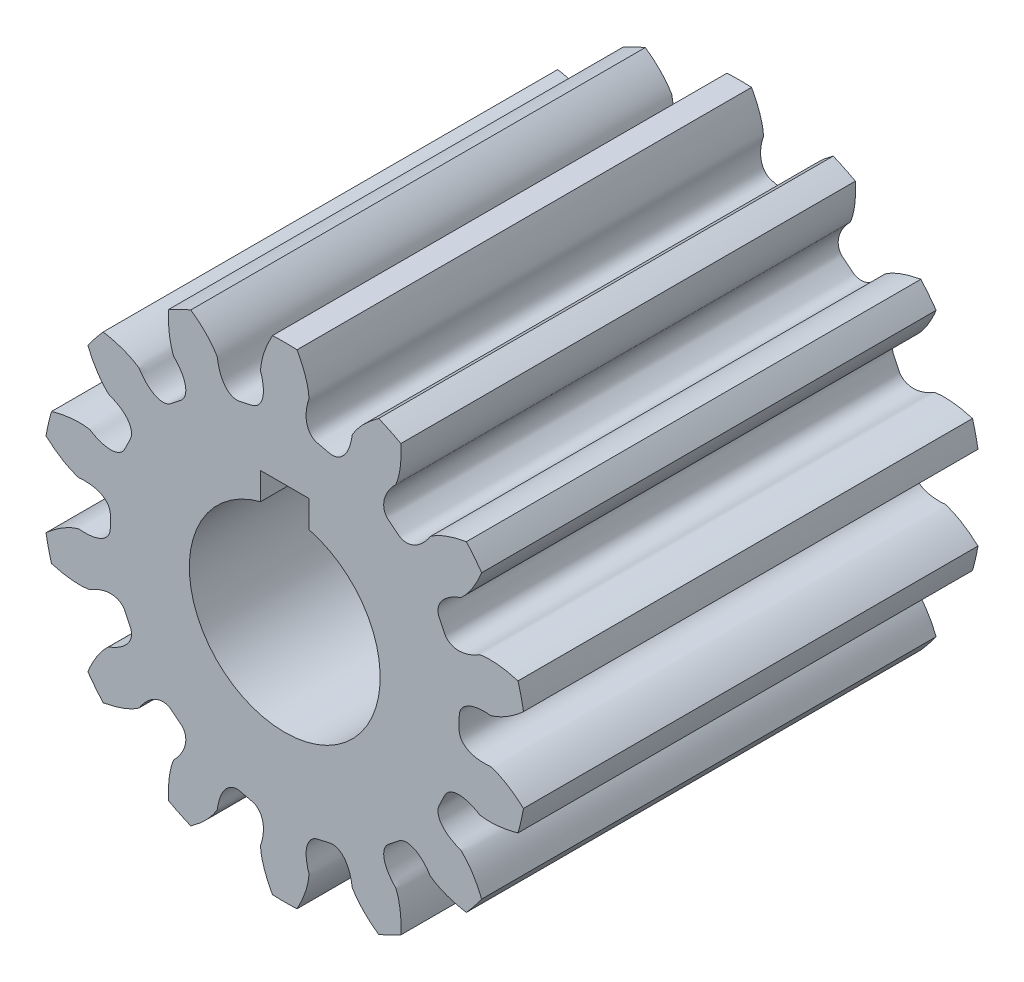
from build123d import *

# Parameters (mm, degrees)
BOSS_EXTRUDE1_DEPTH = 19.05


with BuildPart() as part:
    # Sketch1 → Boss-Extrude1 (new body)
    with BuildSketch(Plane.XY.offset(9.525)):
        with BuildLine():
            ThreePointArc((8.254240281, 5.923944149), (7.943407743, 6.334656292), (7.612159758, 6.729087659))
            add(Edge.make_bspline(
                [(4.866510484, 8.91866989), (4.871788095, 8.831889334), (4.876863236, 8.693415419), (4.875897418, 8.506237979), (4.870472214, 8.36041887), (4.860992929, 8.223670591), (4.848034499, 8.096094305), (4.832174578, 7.977763161), (4.813989816, 7.868724096), (4.794062548, 7.768992217), (4.772953915, 7.67856936), (4.751286261, 7.597384156), (4.729474057, 7.525484762), (4.708567258, 7.462432099), (4.682440878, 7.395927708), (4.653018269, 7.304855443), (4.571118248, 7.24170707), (4.512717244, 7.168958718), (4.466033353, 7.111860953), (4.42312977, 7.054541235), (4.383170204, 6.997585971), (4.346330736, 6.940873063), (4.31253115, 6.884445397), (4.281762968, 6.828283724), (4.254008713, 6.772361484), (4.229267489, 6.716626724), (4.207555117, 6.661002359), (4.188913451, 6.60538159), (4.173420903, 6.549625086), (4.161207451, 6.493559507), (4.152474573, 6.436979817), (4.147521039, 6.37965888), (4.146774005, 6.321370083), (4.150822138, 6.261931608), (4.160440272, 6.201282083), (4.176588359, 6.13959837), (4.200340159, 6.077441385), (4.232748668, 6.015934806), (4.274448355, 5.956743468), (4.321011181, 5.907396991), (4.416018599, 5.826894138), (4.564101629, 5.72320242), (4.698145153, 5.601905718), (4.797770771, 5.527193905), (4.856241232, 5.49277913), (4.923227573, 5.465296254), (4.990403626, 5.447386795), (5.056287478, 5.438061733), (5.120017939, 5.436044429), (5.18128709, 5.440163231), (5.240136113, 5.449442898), (5.296797257, 5.46314168), (5.351578774, 5.480726127), (5.404796645, 5.501830218), (5.456738794, 5.526213219), (5.507649949, 5.553724325), (5.557728029, 5.584275392), (5.607126317, 5.617820974), (5.65595825, 5.654344035), (5.7043025, 5.693846302), (5.752209518, 5.73634021), (5.79970131, 5.781848707), (5.846794754, 5.830384341), (5.89343019, 5.882015776), (5.939765838, 5.936598515), (5.9850439, 5.99481739), (6.042972853, 6.06794219), (6.086313495, 6.161840642), (6.168555242, 6.21079105), (6.227578563, 6.251061007), (6.284398162, 6.285474166), (6.349641217, 6.322738612), (6.423969432, 6.361928421), (6.507428086, 6.402628795), (6.600225244, 6.444248875), (6.702483982, 6.486241182), (6.814319153, 6.528034618), (6.935813313, 6.569056548), (7.067023688, 6.608727522), (7.207979586, 6.64646451), (7.390249182, 6.689057011), (7.526380592, 6.714922459), (7.612159758, 6.729087659)],
                knots=[0.010402665, 0.010402665, 0.010402665, 0.010402665, 0.046486175, 0.067894282, 0.088079069, 0.107040535, 0.124778681, 0.141293506, 0.156585011, 0.170653196, 0.18349806, 0.195119605, 0.205517828, 0.214692732, 0.222644315, 0.235305165, 0.253443912, 0.263936227, 0.274128925, 0.284030449, 0.293650544, 0.303000508, 0.312093491, 0.320944865, 0.329572668, 0.337998146, 0.346246397, 0.354347134, 0.36233556, 0.370253316, 0.378149436, 0.386081099, 0.394113848, 0.402320657, 0.410778894, 0.419563951, 0.428738357, 0.438336273, 0.448346034, 0.458697354, 0.466396858, 0.5, 0.533603142, 0.541302646, 0.551653966, 0.561663727, 0.571261643, 0.580436049, 0.589221106, 0.597679343, 0.605886152, 0.613918901, 0.621850564, 0.629746684, 0.63766444, 0.645652866, 0.653753603, 0.662001854, 0.670427332, 0.679055135, 0.687906509, 0.696999492, 0.706349456, 0.715969551, 0.725871075, 0.736063773, 0.746556088, 0.764694835, 0.777355685, 0.785307268, 0.794482172, 0.804880395, 0.81650194, 0.829346804, 0.843414989, 0.858706494, 0.875221319, 0.892959465, 0.911920931, 0.932105718, 0.953513825, 0.989597335, 0.989597335, 0.989597335, 0.989597335], degree=3))
            ThreePointArc((4.866510484, 8.91866989), (4.408258723, 9.15384356), (3.938677245, 9.365490829))
            add(Edge.make_bspline(
                [(0.514908601, 10.146943679), (0.557316237, 10.071046969), (0.62197036, 9.948488304), (0.702313437, 9.779428205), (0.760694036, 9.64569582), (0.811486351, 9.51837697), (0.855164485, 9.397812256), (0.892217149, 9.284318218), (0.923143522, 9.178187342), (0.948461715, 9.079685906), (0.9686765, 8.989059035), (0.984379558, 8.906512451), (0.99592342, 8.832269374), (1.00444457, 8.766389768), (1.009760689, 8.695135571), (1.022766609, 8.600316304), (0.976376291, 8.507886498), (0.955323132, 8.417003252), (0.938036192, 8.345304562), (0.924251493, 8.275046113), (0.91296113, 8.206393387), (0.904376725, 8.139312777), (0.898407398, 8.073808116), (0.895053859, 8.009858383), (0.894311891, 7.947432066), (0.896203224, 7.886481967), (0.900775561, 7.826945502), (0.908112947, 7.768744604), (0.918346484, 7.711787765), (0.931668487, 7.655975206), (0.948349444, 7.601209613), (0.968757086, 7.547415975), (0.993374593, 7.494575458), (1.022811223, 7.442779661), (1.057791704, 7.39230948), (1.099104188, 7.343740767), (1.147472725, 7.298044778), (1.203358488, 7.25669079), (1.266610767, 7.221454053), (1.329973057, 7.197197267), (1.450500662, 7.165888876), (1.628909012, 7.136716686), (1.802306721, 7.085591439), (1.924482542, 7.061504356), (1.992094618, 7.055867098), (2.064371599, 7.060170166), (2.132665754, 7.073180898), (2.196071047, 7.09336524), (2.254365483, 7.119199323), (2.307779999, 7.149493923), (2.35677484, 7.183388248), (2.401881089, 7.220314773), (2.443607924, 7.259926623), (2.482398847, 7.302031121), (2.518617719, 7.346536299), (2.552550463, 7.393412472), (2.584413643, 7.442666096), (2.61436508, 7.494322736), (2.642514369, 7.548416258), (2.668931643, 7.604982355), (2.693656958, 7.664054119), (2.716700187, 7.725661774), (2.738071092, 7.789823949), (2.757686128, 7.856576622), (2.775750541, 7.925858254), (2.791284442, 7.997957063), (2.811748964, 8.088974663), (2.810056522, 8.192379044), (2.862914989, 8.272165195), (2.898620684, 8.334056431), (2.934882065, 8.389714716), (2.977495588, 8.451596723), (3.027459175, 8.519155324), (3.084993594, 8.592036447), (3.150542668, 8.669798022), (3.224454829, 8.752000187), (3.307081343, 8.838178233), (3.398745051, 8.927852055), (3.499748924, 9.020524416), (3.610372334, 9.115682739), (3.756111372, 9.23314107), (3.867538937, 9.315510239), (3.938677245, 9.365490829)],
                knots=[0.010402665, 0.010402665, 0.010402665, 0.010402665, 0.046486175, 0.067894282, 0.088079069, 0.107040535, 0.124778681, 0.141293506, 0.156585011, 0.170653196, 0.18349806, 0.195119605, 0.205517828, 0.214692732, 0.222644315, 0.235305165, 0.253443912, 0.263936227, 0.274128925, 0.284030449, 0.293650544, 0.303000508, 0.312093491, 0.320944865, 0.329572668, 0.337998146, 0.346246397, 0.354347134, 0.36233556, 0.370253316, 0.378149436, 0.386081099, 0.394113848, 0.402320657, 0.410778894, 0.419563951, 0.428738357, 0.438336273, 0.448346034, 0.458697354, 0.466396858, 0.5, 0.533603142, 0.541302646, 0.551653966, 0.561663727, 0.571261643, 0.580436049, 0.589221106, 0.597679343, 0.605886152, 0.613918901, 0.621850564, 0.629746684, 0.63766444, 0.645652866, 0.653753603, 0.662001854, 0.670427332, 0.679055135, 0.687906509, 0.696999492, 0.706349456, 0.715969551, 0.725871075, 0.736063773, 0.746556088, 0.764694835, 0.777355685, 0.785307268, 0.794482172, 0.804880395, 0.81650194, 0.829346804, 0.843414989, 0.858706494, 0.875221319, 0.892959465, 0.911920931, 0.932105718, 0.953513825, 0.989597335, 0.989597335, 0.989597335, 0.989597335], degree=3))
            ThreePointArc((0.514908601, 10.146943679), (0, 10.159999847), (-0.514908601, 10.146943679))
            add(Edge.make_bspline(
                [(-3.938677245, 9.365490829), (-3.867538937, 9.315510239), (-3.756111372, 9.23314107), (-3.610372334, 9.115682739), (-3.499748924, 9.020524416), (-3.398745051, 8.927852055), (-3.307081343, 8.838178233), (-3.224454829, 8.752000187), (-3.150542669, 8.669798022), (-3.084993594, 8.592036447), (-3.027459175, 8.519155324), (-2.977495588, 8.451596723), (-2.934882065, 8.389714716), (-2.898620684, 8.334056431), (-2.862914989, 8.272165195), (-2.810056522, 8.192379044), (-2.811748964, 8.088974663), (-2.791284442, 7.997957063), (-2.775750541, 7.925858254), (-2.757686128, 7.856576622), (-2.738071092, 7.789823949), (-2.716700187, 7.725661774), (-2.693656958, 7.664054119), (-2.668931643, 7.604982355), (-2.642514369, 7.548416258), (-2.61436508, 7.494322736), (-2.584413643, 7.442666096), (-2.552550463, 7.393412472), (-2.518617719, 7.346536299), (-2.482398847, 7.302031121), (-2.443607924, 7.259926623), (-2.401881089, 7.220314773), (-2.35677484, 7.183388248), (-2.307779999, 7.149493923), (-2.254365483, 7.119199323), (-2.196071047, 7.09336524), (-2.132665754, 7.073180898), (-2.064371599, 7.060170166), (-1.992094618, 7.055867098), (-1.924482542, 7.061504356), (-1.802306721, 7.085591439), (-1.628909012, 7.136716686), (-1.450500662, 7.165888876), (-1.329973057, 7.197197267), (-1.266610767, 7.221454053), (-1.203358488, 7.25669079), (-1.147472726, 7.298044778), (-1.099104188, 7.343740767), (-1.057791705, 7.39230948), (-1.022811223, 7.442779661), (-0.993374593, 7.494575458), (-0.968757086, 7.547415975), (-0.948349444, 7.601209613), (-0.931668487, 7.655975206), (-0.918346484, 7.711787765), (-0.908112947, 7.768744604), (-0.900775561, 7.826945502), (-0.896203224, 7.886481967), (-0.894311891, 7.947432066), (-0.895053859, 8.009858383), (-0.898407398, 8.073808116), (-0.904376725, 8.139312777), (-0.91296113, 8.206393387), (-0.924251493, 8.275046113), (-0.938036192, 8.345304562), (-0.955323132, 8.417003252), (-0.976376291, 8.507886498), (-1.022766609, 8.600316304), (-1.009760689, 8.695135571), (-1.00444457, 8.766389768), (-0.99592342, 8.832269374), (-0.984379558, 8.906512451), (-0.9686765, 8.989059035), (-0.948461715, 9.079685906), (-0.923143522, 9.178187342), (-0.892217149, 9.284318218), (-0.855164485, 9.397812256), (-0.811486351, 9.51837697), (-0.760694037, 9.64569582), (-0.702313437, 9.779428205), (-0.62197036, 9.948488304), (-0.557316237, 10.071046969), (-0.514908601, 10.146943679)],
                knots=[0.010402665, 0.010402665, 0.010402665, 0.010402665, 0.046486175, 0.067894282, 0.088079069, 0.107040535, 0.124778681, 0.141293506, 0.156585011, 0.170653196, 0.18349806, 0.195119605, 0.205517828, 0.214692732, 0.222644315, 0.235305165, 0.253443912, 0.263936227, 0.274128925, 0.284030449, 0.293650544, 0.303000508, 0.312093491, 0.320944865, 0.329572668, 0.337998146, 0.346246397, 0.354347134, 0.36233556, 0.370253316, 0.378149436, 0.386081099, 0.394113848, 0.402320657, 0.410778894, 0.419563951, 0.428738357, 0.438336273, 0.448346034, 0.458697354, 0.466396858, 0.5, 0.533603142, 0.541302646, 0.551653966, 0.561663727, 0.571261643, 0.580436049, 0.589221106, 0.597679343, 0.605886152, 0.613918901, 0.621850564, 0.629746684, 0.63766444, 0.645652866, 0.653753603, 0.662001854, 0.670427332, 0.679055135, 0.687906509, 0.696999492, 0.706349456, 0.715969551, 0.725871075, 0.736063773, 0.746556088, 0.764694835, 0.777355685, 0.785307268, 0.794482172, 0.804880395, 0.81650194, 0.829346804, 0.843414989, 0.858706494, 0.875221319, 0.892959465, 0.911920931, 0.932105718, 0.953513825, 0.989597335, 0.989597335, 0.989597335, 0.989597335], degree=3))
            ThreePointArc((-3.938677245, 9.365490829), (-4.408258723, 9.15384356), (-4.866510484, 8.91866989))
            add(Edge.make_bspline(
                [(-7.612159758, 6.729087659), (-7.526380592, 6.714922459), (-7.390249182, 6.689057011), (-7.207979586, 6.64646451), (-7.067023688, 6.608727522), (-6.935813313, 6.569056548), (-6.814319153, 6.528034618), (-6.702483982, 6.486241182), (-6.600225244, 6.444248875), (-6.507428086, 6.402628795), (-6.423969432, 6.361928421), (-6.349641217, 6.322738612), (-6.284398162, 6.285474166), (-6.227578563, 6.251061007), (-6.168555242, 6.21079105), (-6.086313495, 6.161840642), (-6.042972853, 6.06794219), (-5.9850439, 5.99481739), (-5.939765838, 5.936598515), (-5.89343019, 5.882015776), (-5.846794754, 5.830384341), (-5.79970131, 5.781848707), (-5.752209518, 5.73634021), (-5.704302501, 5.693846302), (-5.65595825, 5.654344035), (-5.607126317, 5.617820974), (-5.557728029, 5.584275392), (-5.507649949, 5.553724325), (-5.456738794, 5.526213219), (-5.404796645, 5.501830218), (-5.351578774, 5.480726127), (-5.296797257, 5.46314168), (-5.240136113, 5.449442898), (-5.18128709, 5.440163231), (-5.120017939, 5.436044429), (-5.056287478, 5.438061733), (-4.990403626, 5.447386795), (-4.923227573, 5.465296254), (-4.856241232, 5.49277913), (-4.797770771, 5.527193905), (-4.698145153, 5.601905718), (-4.564101629, 5.72320242), (-4.416018599, 5.826894138), (-4.321011181, 5.907396991), (-4.274448355, 5.956743468), (-4.232748669, 6.015934806), (-4.200340159, 6.077441385), (-4.176588359, 6.13959837), (-4.160440272, 6.201282083), (-4.150822138, 6.261931608), (-4.146774005, 6.321370083), (-4.147521039, 6.37965888), (-4.152474573, 6.436979817), (-4.161207451, 6.493559507), (-4.173420903, 6.549625086), (-4.188913451, 6.60538159), (-4.207555117, 6.661002359), (-4.229267489, 6.716626724), (-4.254008713, 6.772361484), (-4.281762968, 6.828283724), (-4.31253115, 6.884445397), (-4.346330736, 6.940873063), (-4.383170204, 6.997585971), (-4.42312977, 7.054541235), (-4.466033354, 7.111860953), (-4.512717244, 7.168958718), (-4.571118248, 7.24170707), (-4.653018269, 7.304855443), (-4.682440878, 7.395927708), (-4.708567258, 7.462432099), (-4.729474057, 7.525484762), (-4.751286261, 7.597384156), (-4.772953915, 7.67856936), (-4.794062548, 7.768992217), (-4.813989816, 7.868724096), (-4.832174578, 7.977763161), (-4.848034499, 8.096094305), (-4.860992929, 8.223670591), (-4.870472214, 8.36041887), (-4.875897418, 8.506237979), (-4.876863236, 8.693415419), (-4.871788095, 8.831889334), (-4.866510484, 8.91866989)],
                knots=[0.010402665, 0.010402665, 0.010402665, 0.010402665, 0.046486175, 0.067894282, 0.088079069, 0.107040535, 0.124778681, 0.141293506, 0.156585011, 0.170653196, 0.18349806, 0.195119605, 0.205517828, 0.214692732, 0.222644315, 0.235305165, 0.253443912, 0.263936227, 0.274128925, 0.284030449, 0.293650544, 0.303000508, 0.312093491, 0.320944865, 0.329572668, 0.337998146, 0.346246397, 0.354347134, 0.36233556, 0.370253316, 0.378149436, 0.386081099, 0.394113848, 0.402320657, 0.410778894, 0.419563951, 0.428738357, 0.438336273, 0.448346034, 0.458697354, 0.466396858, 0.5, 0.533603142, 0.541302646, 0.551653966, 0.561663727, 0.571261643, 0.580436049, 0.589221106, 0.597679343, 0.605886152, 0.613918901, 0.621850564, 0.629746684, 0.63766444, 0.645652866, 0.653753603, 0.662001854, 0.670427332, 0.679055135, 0.687906509, 0.696999492, 0.706349456, 0.715969551, 0.725871075, 0.736063773, 0.746556088, 0.764694835, 0.777355685, 0.785307268, 0.794482172, 0.804880395, 0.81650194, 0.829346804, 0.843414989, 0.858706494, 0.875221319, 0.892959465, 0.911920931, 0.932105718, 0.953513825, 0.989597335, 0.989597335, 0.989597335, 0.989597335], degree=3))
            ThreePointArc((-7.612159758, 6.729087659), (-7.943407743, 6.334656292), (-8.254240281, 5.923944149))
            add(Edge.make_bspline(
                [(-9.777960674, 2.759906152), (-9.694530266, 2.784361933), (-9.560657506, 2.820123174), (-9.377958081, 2.860832471), (-9.23458774, 2.887991091), (-9.099158686, 2.909178827), (-8.971897482, 2.924933686), (-8.853003983, 2.935802563), (-8.742652264, 2.942337206), (-8.640986637, 2.945101987), (-8.548133758, 2.94464357), (-8.46416253, 2.941584576), (-8.389212131, 2.936318371), (-8.32308813, 2.929966286), (-8.252437477, 2.919293568), (-8.157101437, 2.910874131), (-8.077311856, 2.845079349), (-7.993392012, 2.804330611), (-7.927337664, 2.771522632), (-7.861908125, 2.742449568), (-7.797489008, 2.71616561), (-7.734000459, 2.692869594), (-7.671466436, 2.672473771), (-7.60986629, 2.654974159), (-7.549170234, 2.64035963), (-7.48932742, 2.628640871), (-7.430266217, 2.61985046), (-7.371891816, 2.614052964), (-7.314085828, 2.611355836), (-7.256708181, 2.611924366), (-7.199603814, 2.616000605), (-7.142617767, 2.623926375), (-7.085624162, 2.636168548), (-7.028576727, 2.653341491), (-6.971588049, 2.676214267), (-6.915044163, 2.705683406), (-6.859730856, 2.742670929), (-6.806977947, 2.787953391), (-6.758549712, 2.841778891), (-6.720801658, 2.898154913), (-6.663458319, 3.008693867), (-6.595317944, 3.176137725), (-6.506889894, 3.333811553), (-6.456220046, 3.447564291), (-6.435679024, 3.512226783), (-6.423791064, 3.583649152), (-6.42127871, 3.653126191), (-6.426847983, 3.719433219), (-6.43906262, 3.782014716), (-6.456711823, 3.840831202), (-6.478853969, 3.896139837), (-6.504817584, 3.948332102), (-6.534151187, 3.997827224), (-6.566568245, 4.04501471), (-6.601898128, 4.090228833), (-6.640048272, 4.133741742), (-6.680976781, 4.175766008), (-6.724673459, 4.216461184), (-6.771146937, 4.255941653), (-6.820416408, 4.29428373), (-6.872505219, 4.331533835), (-6.92744064, 4.367708315), (-6.985238662, 4.402820833), (-7.04595295, 4.436797947), (-7.109477837, 4.469826061), (-7.17631236, 4.501013989), (-7.260494174, 4.541218744), (-7.361682596, 4.562578374), (-7.427706225, 4.631865658), (-7.480100454, 4.680448233), (-7.526294354, 4.728185598), (-7.577142448, 4.783500754), (-7.631889271, 4.847244852), (-7.690140499, 4.919554338), (-7.751366387, 5.000763539), (-7.815060569, 5.09111427), (-7.880691823, 5.190845585), (-7.947720242, 5.300165394), (-8.015593636, 5.419258429), (-8.083750117, 5.548282999), (-8.165833536, 5.716504993), (-8.221342572, 5.8434677), (-8.254240281, 5.923944149)],
                knots=[0.010402665, 0.010402665, 0.010402665, 0.010402665, 0.046486175, 0.067894282, 0.088079069, 0.107040535, 0.124778681, 0.141293506, 0.156585011, 0.170653196, 0.18349806, 0.195119605, 0.205517828, 0.214692732, 0.222644315, 0.235305165, 0.253443912, 0.263936227, 0.274128925, 0.284030449, 0.293650544, 0.303000508, 0.312093491, 0.320944865, 0.329572668, 0.337998146, 0.346246397, 0.354347134, 0.36233556, 0.370253316, 0.378149436, 0.386081099, 0.394113848, 0.402320657, 0.410778894, 0.419563951, 0.428738357, 0.438336273, 0.448346034, 0.458697354, 0.466396858, 0.5, 0.533603142, 0.541302646, 0.551653966, 0.561663727, 0.571261643, 0.580436049, 0.589221106, 0.597679343, 0.605886152, 0.613918901, 0.621850564, 0.629746684, 0.63766444, 0.645652866, 0.653753603, 0.662001854, 0.670427332, 0.679055135, 0.687906509, 0.696999492, 0.706349456, 0.715969551, 0.725871075, 0.736063773, 0.746556088, 0.764694835, 0.777355685, 0.785307268, 0.794482172, 0.804880395, 0.81650194, 0.829346804, 0.843414989, 0.858706494, 0.875221319, 0.892959465, 0.911920931, 0.932105718, 0.953513825, 0.989597335, 0.989597335, 0.989597335, 0.989597335], degree=3))
            ThreePointArc((-9.777960674, 2.759906152), (-9.905267439, 2.260812655), (-10.007116559, 1.755908617))
            add(Edge.make_bspline(
                [(-10.007116559, -1.755908617), (-9.942559325, -1.697675622), (-9.837460357, -1.607370644), (-9.690516965, -1.491422525), (-9.573128435, -1.404747394), (-9.460304088, -1.326897439), (-9.352481482, -1.257486235), (-9.250077969, -1.196107759), (-9.153489782, -1.142340433), (-9.06309181, -1.095738389), (-8.979235357, -1.055864054), (-8.902252647, -1.022186361), (-8.83243975, -0.99441129), (-8.770108018, -0.971444191), (-8.70182326, -0.950405808), (-8.612275399, -0.916626702), (-8.511840185, -0.94128635), (-8.418550803, -0.941588238), (-8.344803043, -0.942487299), (-8.273238735, -0.940292412), (-8.203794935, -0.936023032), (-8.136485966, -0.929465368), (-8.071295343, -0.920708874), (-8.008202731, -0.909748178), (-7.947176468, -0.896580381), (-7.888175377, -0.881173795), (-7.831149056, -0.863467986), (-7.776040098, -0.843363646), (-7.722788462, -0.820712596), (-7.671339665, -0.79530514), (-7.621659022, -0.766855919), (-7.57375523, -0.734989728), (-7.527717446, -0.699231313), (-7.483770545, -0.659007071), (-7.442349645, -0.613672951), (-7.404191544, -0.562588703), (-7.370404261, -0.505264552), (-7.342522856, -0.441577834), (-7.322244534, -0.37207051), (-7.312695352, -0.304899202), (-7.308991843, -0.180426704), (-7.320250653, 0), (-7.308991843, 0.180426704), (-7.312695352, 0.304899202), (-7.322244534, 0.37207051), (-7.342522856, 0.441577834), (-7.370404261, 0.505264552), (-7.404191544, 0.562588703), (-7.442349645, 0.613672951), (-7.483770545, 0.659007071), (-7.527717446, 0.699231313), (-7.57375523, 0.734989728), (-7.621659022, 0.766855919), (-7.671339665, 0.79530514), (-7.722788462, 0.820712596), (-7.776040098, 0.843363646), (-7.831149056, 0.863467986), (-7.888175377, 0.881173795), (-7.947176468, 0.896580381), (-8.008202731, 0.909748178), (-8.071295343, 0.920708874), (-8.136485966, 0.929465368), (-8.203794935, 0.936023032), (-8.273238735, 0.940292412), (-8.344803043, 0.942487299), (-8.418550803, 0.941588238), (-8.511840185, 0.94128635), (-8.612275399, 0.916626702), (-8.70182326, 0.950405808), (-8.770108018, 0.971444191), (-8.83243975, 0.99441129), (-8.902252647, 1.022186361), (-8.979235357, 1.055864054), (-9.06309181, 1.095738389), (-9.153489782, 1.142340433), (-9.250077969, 1.196107759), (-9.352481482, 1.257486235), (-9.460304088, 1.326897439), (-9.573128435, 1.404747394), (-9.690516965, 1.491422525), (-9.837460357, 1.607370644), (-9.942559325, 1.697675622), (-10.007116559, 1.755908617)],
                knots=[0.010402665, 0.010402665, 0.010402665, 0.010402665, 0.046486175, 0.067894282, 0.088079069, 0.107040535, 0.124778681, 0.141293506, 0.156585011, 0.170653196, 0.18349806, 0.195119605, 0.205517828, 0.214692732, 0.222644315, 0.235305165, 0.253443912, 0.263936227, 0.274128925, 0.284030449, 0.293650544, 0.303000508, 0.312093491, 0.320944865, 0.329572668, 0.337998146, 0.346246397, 0.354347134, 0.36233556, 0.370253316, 0.378149436, 0.386081099, 0.394113848, 0.402320657, 0.410778894, 0.419563951, 0.428738357, 0.438336273, 0.448346034, 0.458697354, 0.466396858, 0.5, 0.533603142, 0.541302646, 0.551653966, 0.561663727, 0.571261643, 0.580436049, 0.589221106, 0.597679343, 0.605886152, 0.613918901, 0.621850564, 0.629746684, 0.63766444, 0.645652866, 0.653753603, 0.662001854, 0.670427332, 0.679055135, 0.687906509, 0.696999492, 0.706349456, 0.715969551, 0.725871075, 0.736063773, 0.746556088, 0.764694835, 0.777355685, 0.785307268, 0.794482172, 0.804880395, 0.81650194, 0.829346804, 0.843414989, 0.858706494, 0.875221319, 0.892959465, 0.911920931, 0.932105718, 0.953513825, 0.989597335, 0.989597335, 0.989597335, 0.989597335], degree=3))
            ThreePointArc((-10.007116559, -1.755908617), (-9.905267439, -2.260812655), (-9.777960674, -2.759906152))
            add(Edge.make_bspline(
                [(-8.254240281, -5.923944149), (-8.221342572, -5.8434677), (-8.165833536, -5.716504993), (-8.083750117, -5.548282999), (-8.015593636, -5.419258429), (-7.947720242, -5.300165394), (-7.880691823, -5.190845585), (-7.815060569, -5.09111427), (-7.751366387, -5.000763539), (-7.690140499, -4.919554338), (-7.631889271, -4.847244852), (-7.577142448, -4.783500754), (-7.526294354, -4.728185598), (-7.480100454, -4.680448233), (-7.427706225, -4.631865658), (-7.361682596, -4.562578374), (-7.260494174, -4.541218744), (-7.17631236, -4.501013989), (-7.109477837, -4.469826061), (-7.04595295, -4.436797947), (-6.985238662, -4.402820833), (-6.92744064, -4.367708315), (-6.872505219, -4.331533835), (-6.820416408, -4.29428373), (-6.771146937, -4.255941653), (-6.724673459, -4.216461184), (-6.680976781, -4.175766008), (-6.640048272, -4.133741742), (-6.601898128, -4.090228833), (-6.566568245, -4.04501471), (-6.534151187, -3.997827224), (-6.504817584, -3.948332102), (-6.478853969, -3.896139837), (-6.456711823, -3.840831202), (-6.439062619, -3.782014716), (-6.426847983, -3.719433219), (-6.42127871, -3.653126191), (-6.423791064, -3.583649152), (-6.435679024, -3.512226784), (-6.456220046, -3.447564291), (-6.506889894, -3.333811553), (-6.595317944, -3.176137725), (-6.663458319, -3.008693867), (-6.720801658, -2.898154913), (-6.758549712, -2.841778891), (-6.806977947, -2.787953391), (-6.859730856, -2.742670929), (-6.915044163, -2.705683406), (-6.971588049, -2.676214267), (-7.028576727, -2.653341491), (-7.085624162, -2.636168548), (-7.142617767, -2.623926375), (-7.199603814, -2.616000606), (-7.256708181, -2.611924366), (-7.314085828, -2.611355836), (-7.371891816, -2.614052964), (-7.430266217, -2.61985046), (-7.48932742, -2.628640871), (-7.549170234, -2.64035963), (-7.60986629, -2.654974159), (-7.671466436, -2.672473771), (-7.734000459, -2.692869594), (-7.797489008, -2.71616561), (-7.861908125, -2.742449568), (-7.927337664, -2.771522632), (-7.993392012, -2.804330611), (-8.077311856, -2.845079349), (-8.157101437, -2.910874131), (-8.252437477, -2.919293568), (-8.32308813, -2.929966286), (-8.389212131, -2.936318371), (-8.46416253, -2.941584576), (-8.548133758, -2.94464357), (-8.640986637, -2.945101987), (-8.742652264, -2.942337206), (-8.853003983, -2.935802563), (-8.971897482, -2.924933686), (-9.099158686, -2.909178827), (-9.23458774, -2.887991091), (-9.377958081, -2.860832471), (-9.560657506, -2.820123174), (-9.694530266, -2.784361933), (-9.777960674, -2.759906152)],
                knots=[0.010402665, 0.010402665, 0.010402665, 0.010402665, 0.046486175, 0.067894282, 0.088079069, 0.107040535, 0.124778681, 0.141293506, 0.156585011, 0.170653196, 0.18349806, 0.195119605, 0.205517828, 0.214692732, 0.222644315, 0.235305165, 0.253443912, 0.263936227, 0.274128925, 0.284030449, 0.293650544, 0.303000508, 0.312093491, 0.320944865, 0.329572668, 0.337998146, 0.346246397, 0.354347134, 0.36233556, 0.370253316, 0.378149436, 0.386081099, 0.394113848, 0.402320657, 0.410778894, 0.419563951, 0.428738357, 0.438336273, 0.448346034, 0.458697354, 0.466396858, 0.5, 0.533603142, 0.541302646, 0.551653966, 0.561663727, 0.571261643, 0.580436049, 0.589221106, 0.597679343, 0.605886152, 0.613918901, 0.621850564, 0.629746684, 0.63766444, 0.645652866, 0.653753603, 0.662001854, 0.670427332, 0.679055135, 0.687906509, 0.696999492, 0.706349456, 0.715969551, 0.725871075, 0.736063773, 0.746556088, 0.764694835, 0.777355685, 0.785307268, 0.794482172, 0.804880395, 0.81650194, 0.829346804, 0.843414989, 0.858706494, 0.875221319, 0.892959465, 0.911920931, 0.932105718, 0.953513825, 0.989597335, 0.989597335, 0.989597335, 0.989597335], degree=3))
            ThreePointArc((-8.254240281, -5.923944149), (-7.943407743, -6.334656292), (-7.612159758, -6.729087659))
            add(Edge.make_bspline(
                [(-4.866510484, -8.91866989), (-4.871788095, -8.831889334), (-4.876863236, -8.693415419), (-4.875897418, -8.506237979), (-4.870472214, -8.36041887), (-4.860992929, -8.223670591), (-4.848034499, -8.096094305), (-4.832174578, -7.977763161), (-4.813989816, -7.868724096), (-4.794062548, -7.768992217), (-4.772953915, -7.67856936), (-4.751286261, -7.597384156), (-4.729474057, -7.525484762), (-4.708567258, -7.462432099), (-4.682440878, -7.395927708), (-4.653018269, -7.304855443), (-4.571118248, -7.24170707), (-4.512717244, -7.168958718), (-4.466033354, -7.111860953), (-4.42312977, -7.054541235), (-4.383170204, -6.997585971), (-4.346330736, -6.940873063), (-4.31253115, -6.884445397), (-4.281762968, -6.828283724), (-4.254008713, -6.772361484), (-4.229267489, -6.716626724), (-4.207555117, -6.661002359), (-4.188913451, -6.60538159), (-4.173420903, -6.549625086), (-4.161207451, -6.493559507), (-4.152474573, -6.436979817), (-4.147521039, -6.37965888), (-4.146774005, -6.321370083), (-4.150822138, -6.261931608), (-4.160440272, -6.201282083), (-4.176588359, -6.13959837), (-4.200340159, -6.077441385), (-4.232748668, -6.015934806), (-4.274448355, -5.956743468), (-4.321011181, -5.907396991), (-4.416018599, -5.826894138), (-4.564101629, -5.72320242), (-4.698145153, -5.601905718), (-4.797770771, -5.527193905), (-4.856241232, -5.49277913), (-4.923227573, -5.465296254), (-4.990403626, -5.447386795), (-5.056287478, -5.438061733), (-5.120017939, -5.436044429), (-5.18128709, -5.440163231), (-5.240136113, -5.449442898), (-5.296797257, -5.46314168), (-5.351578774, -5.480726127), (-5.404796645, -5.501830218), (-5.456738794, -5.526213219), (-5.507649949, -5.553724325), (-5.557728029, -5.584275392), (-5.607126317, -5.617820975), (-5.65595825, -5.654344035), (-5.704302501, -5.693846302), (-5.752209518, -5.73634021), (-5.79970131, -5.781848707), (-5.846794754, -5.830384341), (-5.89343019, -5.882015776), (-5.939765838, -5.936598515), (-5.9850439, -5.99481739), (-6.042972853, -6.06794219), (-6.086313495, -6.161840642), (-6.168555242, -6.21079105), (-6.227578563, -6.251061007), (-6.284398162, -6.285474166), (-6.349641217, -6.322738612), (-6.423969432, -6.361928421), (-6.507428086, -6.402628795), (-6.600225244, -6.444248875), (-6.702483982, -6.486241182), (-6.814319153, -6.528034618), (-6.935813313, -6.569056548), (-7.067023688, -6.608727522), (-7.207979586, -6.64646451), (-7.390249182, -6.689057011), (-7.526380592, -6.714922459), (-7.612159758, -6.729087659)],
                knots=[0.010402665, 0.010402665, 0.010402665, 0.010402665, 0.046486175, 0.067894282, 0.088079069, 0.107040535, 0.124778681, 0.141293506, 0.156585011, 0.170653196, 0.18349806, 0.195119605, 0.205517828, 0.214692732, 0.222644315, 0.235305165, 0.253443912, 0.263936227, 0.274128925, 0.284030449, 0.293650544, 0.303000508, 0.312093491, 0.320944865, 0.329572668, 0.337998146, 0.346246397, 0.354347134, 0.36233556, 0.370253316, 0.378149436, 0.386081099, 0.394113848, 0.402320657, 0.410778894, 0.419563951, 0.428738357, 0.438336273, 0.448346034, 0.458697354, 0.466396858, 0.5, 0.533603142, 0.541302646, 0.551653966, 0.561663727, 0.571261643, 0.580436049, 0.589221106, 0.597679343, 0.605886152, 0.613918901, 0.621850564, 0.629746684, 0.63766444, 0.645652866, 0.653753603, 0.662001854, 0.670427332, 0.679055135, 0.687906509, 0.696999492, 0.706349456, 0.715969551, 0.725871075, 0.736063773, 0.746556088, 0.764694835, 0.777355685, 0.785307268, 0.794482172, 0.804880395, 0.81650194, 0.829346804, 0.843414989, 0.858706494, 0.875221319, 0.892959465, 0.911920931, 0.932105718, 0.953513825, 0.989597335, 0.989597335, 0.989597335, 0.989597335], degree=3))
            ThreePointArc((-4.866510484, -8.91866989), (-4.408258723, -9.15384356), (-3.938677245, -9.365490829))
            add(Edge.make_bspline(
                [(-0.514908601, -10.146943679), (-0.557316237, -10.071046969), (-0.62197036, -9.948488304), (-0.702313437, -9.779428205), (-0.760694036, -9.64569582), (-0.811486351, -9.51837697), (-0.855164485, -9.397812256), (-0.892217149, -9.284318218), (-0.923143522, -9.178187342), (-0.948461715, -9.079685906), (-0.9686765, -8.989059035), (-0.984379558, -8.906512451), (-0.99592342, -8.832269374), (-1.00444457, -8.766389768), (-1.009760689, -8.695135571), (-1.022766609, -8.600316304), (-0.976376291, -8.507886498), (-0.955323132, -8.417003252), (-0.938036192, -8.345304562), (-0.924251493, -8.275046113), (-0.91296113, -8.206393387), (-0.904376725, -8.139312777), (-0.898407398, -8.073808116), (-0.895053859, -8.009858383), (-0.894311891, -7.947432066), (-0.896203224, -7.886481967), (-0.900775561, -7.826945502), (-0.908112947, -7.768744604), (-0.918346484, -7.711787765), (-0.931668487, -7.655975206), (-0.948349444, -7.601209613), (-0.968757086, -7.547415975), (-0.993374593, -7.494575458), (-1.022811223, -7.442779661), (-1.057791704, -7.39230948), (-1.099104188, -7.343740767), (-1.147472726, -7.298044778), (-1.203358488, -7.25669079), (-1.266610767, -7.221454053), (-1.329973057, -7.197197267), (-1.450500662, -7.165888877), (-1.628909012, -7.136716686), (-1.802306721, -7.085591439), (-1.924482542, -7.061504356), (-1.992094618, -7.055867098), (-2.064371599, -7.060170166), (-2.132665754, -7.073180898), (-2.196071047, -7.09336524), (-2.254365483, -7.119199323), (-2.307779999, -7.149493923), (-2.35677484, -7.183388248), (-2.401881089, -7.220314773), (-2.443607924, -7.259926623), (-2.482398847, -7.302031121), (-2.518617719, -7.346536299), (-2.552550463, -7.393412472), (-2.584413643, -7.442666096), (-2.61436508, -7.494322736), (-2.642514369, -7.548416258), (-2.668931643, -7.604982355), (-2.693656958, -7.664054119), (-2.716700187, -7.725661774), (-2.738071092, -7.789823949), (-2.757686128, -7.856576622), (-2.775750541, -7.925858254), (-2.791284442, -7.997957063), (-2.811748964, -8.088974663), (-2.810056522, -8.192379044), (-2.862914989, -8.272165195), (-2.898620684, -8.334056431), (-2.934882065, -8.389714716), (-2.977495588, -8.451596723), (-3.027459175, -8.519155324), (-3.084993594, -8.592036447), (-3.150542668, -8.669798022), (-3.224454829, -8.752000187), (-3.307081343, -8.838178233), (-3.398745051, -8.927852055), (-3.499748924, -9.020524416), (-3.610372334, -9.115682739), (-3.756111372, -9.23314107), (-3.867538937, -9.315510239), (-3.938677245, -9.365490829)],
                knots=[0.010402665, 0.010402665, 0.010402665, 0.010402665, 0.046486175, 0.067894282, 0.088079069, 0.107040535, 0.124778681, 0.141293506, 0.156585011, 0.170653196, 0.18349806, 0.195119605, 0.205517828, 0.214692732, 0.222644315, 0.235305165, 0.253443912, 0.263936227, 0.274128925, 0.284030449, 0.293650544, 0.303000508, 0.312093491, 0.320944865, 0.329572668, 0.337998146, 0.346246397, 0.354347134, 0.36233556, 0.370253316, 0.378149436, 0.386081099, 0.394113848, 0.402320657, 0.410778894, 0.419563951, 0.428738357, 0.438336273, 0.448346034, 0.458697354, 0.466396858, 0.5, 0.533603142, 0.541302646, 0.551653966, 0.561663727, 0.571261643, 0.580436049, 0.589221106, 0.597679343, 0.605886152, 0.613918901, 0.621850564, 0.629746684, 0.63766444, 0.645652866, 0.653753603, 0.662001854, 0.670427332, 0.679055135, 0.687906509, 0.696999492, 0.706349456, 0.715969551, 0.725871075, 0.736063773, 0.746556088, 0.764694835, 0.777355685, 0.785307268, 0.794482172, 0.804880395, 0.81650194, 0.829346804, 0.843414989, 0.858706494, 0.875221319, 0.892959465, 0.911920931, 0.932105718, 0.953513825, 0.989597335, 0.989597335, 0.989597335, 0.989597335], degree=3))
            ThreePointArc((-0.514908601, -10.146943679), (0, -10.159999847), (0.514908601, -10.146943679))
            add(Edge.make_bspline(
                [(3.938677245, -9.365490829), (3.867538937, -9.315510239), (3.756111372, -9.23314107), (3.610372334, -9.115682739), (3.499748924, -9.020524416), (3.398745051, -8.927852055), (3.307081343, -8.838178233), (3.224454829, -8.752000187), (3.150542669, -8.669798022), (3.084993594, -8.592036447), (3.027459175, -8.519155324), (2.977495588, -8.451596723), (2.934882065, -8.389714716), (2.898620684, -8.334056431), (2.862914989, -8.272165195), (2.810056522, -8.192379044), (2.811748964, -8.088974663), (2.791284442, -7.997957063), (2.775750541, -7.925858254), (2.757686128, -7.856576622), (2.738071092, -7.789823949), (2.716700187, -7.725661774), (2.693656958, -7.664054119), (2.668931643, -7.604982355), (2.642514369, -7.548416258), (2.61436508, -7.494322736), (2.584413643, -7.442666096), (2.552550463, -7.393412472), (2.518617719, -7.346536299), (2.482398847, -7.302031121), (2.443607924, -7.259926623), (2.401881089, -7.220314773), (2.35677484, -7.183388248), (2.307779999, -7.149493923), (2.254365483, -7.119199323), (2.196071047, -7.09336524), (2.132665754, -7.073180898), (2.064371599, -7.060170166), (1.992094618, -7.055867098), (1.924482542, -7.061504356), (1.802306721, -7.085591439), (1.628909012, -7.136716686), (1.450500662, -7.165888876), (1.329973057, -7.197197267), (1.266610767, -7.221454053), (1.203358488, -7.25669079), (1.147472726, -7.298044778), (1.099104188, -7.343740767), (1.057791705, -7.39230948), (1.022811223, -7.442779661), (0.993374593, -7.494575458), (0.968757086, -7.547415975), (0.948349444, -7.601209613), (0.931668487, -7.655975206), (0.918346484, -7.711787765), (0.908112947, -7.768744604), (0.900775561, -7.826945502), (0.896203224, -7.886481967), (0.894311891, -7.947432066), (0.895053859, -8.009858383), (0.898407398, -8.073808116), (0.904376725, -8.139312777), (0.91296113, -8.206393387), (0.924251493, -8.275046113), (0.938036192, -8.345304562), (0.955323132, -8.417003252), (0.976376291, -8.507886498), (1.022766609, -8.600316304), (1.009760689, -8.695135571), (1.00444457, -8.766389768), (0.99592342, -8.832269374), (0.984379558, -8.906512451), (0.9686765, -8.989059035), (0.948461715, -9.079685906), (0.923143522, -9.178187342), (0.892217149, -9.284318218), (0.855164485, -9.397812256), (0.811486351, -9.51837697), (0.760694036, -9.64569582), (0.702313437, -9.779428205), (0.62197036, -9.948488304), (0.557316237, -10.071046969), (0.514908601, -10.146943679)],
                knots=[0.010402665, 0.010402665, 0.010402665, 0.010402665, 0.046486175, 0.067894282, 0.088079069, 0.107040535, 0.124778681, 0.141293506, 0.156585011, 0.170653196, 0.18349806, 0.195119605, 0.205517828, 0.214692732, 0.222644315, 0.235305165, 0.253443912, 0.263936227, 0.274128925, 0.284030449, 0.293650544, 0.303000508, 0.312093491, 0.320944865, 0.329572668, 0.337998146, 0.346246397, 0.354347134, 0.36233556, 0.370253316, 0.378149436, 0.386081099, 0.394113848, 0.402320657, 0.410778894, 0.419563951, 0.428738357, 0.438336273, 0.448346034, 0.458697354, 0.466396858, 0.5, 0.533603142, 0.541302646, 0.551653966, 0.561663727, 0.571261643, 0.580436049, 0.589221106, 0.597679343, 0.605886152, 0.613918901, 0.621850564, 0.629746684, 0.63766444, 0.645652866, 0.653753603, 0.662001854, 0.670427332, 0.679055135, 0.687906509, 0.696999492, 0.706349456, 0.715969551, 0.725871075, 0.736063773, 0.746556088, 0.764694835, 0.777355685, 0.785307268, 0.794482172, 0.804880395, 0.81650194, 0.829346804, 0.843414989, 0.858706494, 0.875221319, 0.892959465, 0.911920931, 0.932105718, 0.953513825, 0.989597335, 0.989597335, 0.989597335, 0.989597335], degree=3))
            ThreePointArc((3.938677245, -9.365490829), (4.408258723, -9.15384356), (4.866510484, -8.91866989))
            add(Edge.make_bspline(
                [(7.612159758, -6.729087659), (7.526380592, -6.714922459), (7.390249182, -6.689057011), (7.207979586, -6.64646451), (7.067023688, -6.608727522), (6.935813313, -6.569056548), (6.814319153, -6.528034618), (6.702483982, -6.486241182), (6.600225244, -6.444248875), (6.507428086, -6.402628795), (6.423969432, -6.361928421), (6.349641217, -6.322738612), (6.284398162, -6.285474166), (6.227578563, -6.251061007), (6.168555242, -6.21079105), (6.086313495, -6.161840642), (6.042972853, -6.06794219), (5.9850439, -5.99481739), (5.939765838, -5.936598514), (5.89343019, -5.882015776), (5.846794754, -5.830384341), (5.79970131, -5.781848707), (5.752209518, -5.73634021), (5.704302501, -5.693846302), (5.65595825, -5.654344035), (5.607126317, -5.617820974), (5.557728029, -5.584275392), (5.507649949, -5.553724325), (5.456738794, -5.526213219), (5.404796645, -5.501830218), (5.351578774, -5.480726127), (5.296797257, -5.46314168), (5.240136113, -5.449442898), (5.18128709, -5.440163231), (5.120017939, -5.436044429), (5.056287478, -5.438061733), (4.990403626, -5.447386795), (4.923227573, -5.465296254), (4.856241232, -5.49277913), (4.797770771, -5.527193905), (4.698145153, -5.601905718), (4.564101629, -5.72320242), (4.416018599, -5.826894138), (4.321011181, -5.907396991), (4.274448355, -5.956743468), (4.232748668, -6.015934806), (4.200340159, -6.077441385), (4.176588359, -6.13959837), (4.160440272, -6.201282083), (4.150822138, -6.261931608), (4.146774005, -6.321370083), (4.147521039, -6.37965888), (4.152474573, -6.436979817), (4.161207451, -6.493559507), (4.173420903, -6.549625086), (4.188913451, -6.60538159), (4.207555117, -6.661002359), (4.229267489, -6.716626724), (4.254008713, -6.772361484), (4.281762968, -6.828283724), (4.31253115, -6.884445397), (4.346330736, -6.940873063), (4.383170204, -6.997585971), (4.42312977, -7.054541235), (4.466033354, -7.111860953), (4.512717244, -7.168958718), (4.571118248, -7.24170707), (4.653018269, -7.304855443), (4.682440878, -7.395927708), (4.708567258, -7.462432099), (4.729474057, -7.525484762), (4.751286261, -7.597384156), (4.772953915, -7.67856936), (4.794062548, -7.768992217), (4.813989816, -7.868724096), (4.832174578, -7.977763161), (4.848034499, -8.096094305), (4.860992929, -8.223670591), (4.870472214, -8.36041887), (4.875897418, -8.506237979), (4.876863236, -8.693415419), (4.871788095, -8.831889334), (4.866510484, -8.91866989)],
                knots=[0.010402665, 0.010402665, 0.010402665, 0.010402665, 0.046486175, 0.067894282, 0.088079069, 0.107040535, 0.124778681, 0.141293506, 0.156585011, 0.170653196, 0.18349806, 0.195119605, 0.205517828, 0.214692732, 0.222644315, 0.235305165, 0.253443912, 0.263936227, 0.274128925, 0.284030449, 0.293650544, 0.303000508, 0.312093491, 0.320944865, 0.329572668, 0.337998146, 0.346246397, 0.354347134, 0.36233556, 0.370253316, 0.378149436, 0.386081099, 0.394113848, 0.402320657, 0.410778894, 0.419563951, 0.428738357, 0.438336273, 0.448346034, 0.458697354, 0.466396858, 0.5, 0.533603142, 0.541302646, 0.551653966, 0.561663727, 0.571261643, 0.580436049, 0.589221106, 0.597679343, 0.605886152, 0.613918901, 0.621850564, 0.629746684, 0.63766444, 0.645652866, 0.653753603, 0.662001854, 0.670427332, 0.679055135, 0.687906509, 0.696999492, 0.706349456, 0.715969551, 0.725871075, 0.736063773, 0.746556088, 0.764694835, 0.777355685, 0.785307268, 0.794482172, 0.804880395, 0.81650194, 0.829346804, 0.843414989, 0.858706494, 0.875221319, 0.892959465, 0.911920931, 0.932105718, 0.953513825, 0.989597335, 0.989597335, 0.989597335, 0.989597335], degree=3))
            ThreePointArc((7.612159758, -6.729087659), (7.943407743, -6.334656292), (8.254240281, -5.923944149))
            add(Edge.make_bspline(
                [(9.777960674, -2.759906152), (9.694530266, -2.784361933), (9.560657506, -2.820123174), (9.377958081, -2.860832471), (9.23458774, -2.887991091), (9.099158686, -2.909178827), (8.971897482, -2.924933686), (8.853003983, -2.935802563), (8.742652264, -2.942337206), (8.640986637, -2.945101987), (8.548133758, -2.94464357), (8.46416253, -2.941584576), (8.389212131, -2.936318371), (8.32308813, -2.929966286), (8.252437476, -2.919293568), (8.157101437, -2.910874131), (8.077311856, -2.845079349), (7.993392011, -2.804330611), (7.927337664, -2.771522632), (7.861908125, -2.742449567), (7.797489008, -2.71616561), (7.734000459, -2.692869594), (7.671466436, -2.672473771), (7.60986629, -2.654974159), (7.549170234, -2.64035963), (7.48932742, -2.628640871), (7.430266217, -2.61985046), (7.371891816, -2.614052964), (7.314085828, -2.611355836), (7.256708181, -2.611924366), (7.199603814, -2.616000605), (7.142617767, -2.623926375), (7.085624162, -2.636168548), (7.028576727, -2.653341491), (6.971588049, -2.676214267), (6.915044163, -2.705683406), (6.859730856, -2.742670929), (6.806977947, -2.787953391), (6.758549712, -2.841778891), (6.720801658, -2.898154913), (6.663458319, -3.008693867), (6.595317944, -3.176137725), (6.506889894, -3.333811553), (6.456220046, -3.447564291), (6.435679024, -3.512226783), (6.423791064, -3.583649152), (6.42127871, -3.653126191), (6.426847983, -3.719433219), (6.439062619, -3.782014716), (6.456711823, -3.840831202), (6.478853969, -3.896139837), (6.504817584, -3.948332102), (6.534151187, -3.997827224), (6.566568245, -4.04501471), (6.601898128, -4.090228833), (6.640048272, -4.133741742), (6.680976781, -4.175766008), (6.724673459, -4.216461184), (6.771146937, -4.255941652), (6.820416407, -4.29428373), (6.872505219, -4.331533835), (6.92744064, -4.367708315), (6.985238662, -4.402820833), (7.04595295, -4.436797947), (7.109477837, -4.469826061), (7.17631236, -4.501013989), (7.260494174, -4.541218744), (7.361682596, -4.562578374), (7.427706225, -4.631865658), (7.480100454, -4.680448233), (7.526294354, -4.728185598), (7.577142448, -4.783500754), (7.631889271, -4.847244852), (7.690140499, -4.919554338), (7.751366387, -5.000763539), (7.815060569, -5.09111427), (7.880691823, -5.190845585), (7.947720242, -5.300165394), (8.015593636, -5.419258429), (8.083750117, -5.548282999), (8.165833536, -5.716504993), (8.221342572, -5.8434677), (8.254240281, -5.923944149)],
                knots=[0.010402665, 0.010402665, 0.010402665, 0.010402665, 0.046486175, 0.067894282, 0.088079069, 0.107040535, 0.124778681, 0.141293506, 0.156585011, 0.170653196, 0.18349806, 0.195119605, 0.205517828, 0.214692732, 0.222644315, 0.235305165, 0.253443912, 0.263936227, 0.274128925, 0.284030449, 0.293650544, 0.303000508, 0.312093491, 0.320944865, 0.329572668, 0.337998146, 0.346246397, 0.354347134, 0.36233556, 0.370253316, 0.378149436, 0.386081099, 0.394113848, 0.402320657, 0.410778894, 0.419563951, 0.428738357, 0.438336273, 0.448346034, 0.458697354, 0.466396858, 0.5, 0.533603142, 0.541302646, 0.551653966, 0.561663727, 0.571261643, 0.580436049, 0.589221106, 0.597679343, 0.605886152, 0.613918901, 0.621850564, 0.629746684, 0.63766444, 0.645652866, 0.653753603, 0.662001854, 0.670427332, 0.679055135, 0.687906509, 0.696999492, 0.706349456, 0.715969551, 0.725871075, 0.736063773, 0.746556088, 0.764694835, 0.777355685, 0.785307268, 0.794482172, 0.804880395, 0.81650194, 0.829346804, 0.843414989, 0.858706494, 0.875221319, 0.892959465, 0.911920931, 0.932105718, 0.953513825, 0.989597335, 0.989597335, 0.989597335, 0.989597335], degree=3))
            ThreePointArc((9.777960674, -2.759906152), (9.905267439, -2.260812655), (10.007116559, -1.755908617))
            add(Edge.make_bspline(
                [(10.007116559, 1.755908617), (9.942559325, 1.697675622), (9.837460357, 1.607370644), (9.690516965, 1.491422525), (9.573128435, 1.404747394), (9.460304088, 1.326897439), (9.352481482, 1.257486235), (9.250077969, 1.196107759), (9.153489781, 1.142340433), (9.06309181, 1.095738389), (8.979235357, 1.055864054), (8.902252647, 1.022186361), (8.83243975, 0.99441129), (8.770108018, 0.971444191), (8.70182326, 0.950405808), (8.612275399, 0.916626702), (8.511840185, 0.94128635), (8.418550803, 0.941588238), (8.344803043, 0.942487299), (8.273238735, 0.940292412), (8.203794935, 0.936023032), (8.136485966, 0.929465368), (8.071295343, 0.920708874), (8.008202731, 0.909748178), (7.947176468, 0.896580381), (7.888175377, 0.881173795), (7.831149056, 0.863467986), (7.776040098, 0.843363646), (7.722788462, 0.820712596), (7.671339665, 0.79530514), (7.621659022, 0.766855919), (7.57375523, 0.734989728), (7.527717446, 0.699231313), (7.483770544, 0.659007071), (7.442349645, 0.613672952), (7.404191544, 0.562588703), (7.370404261, 0.505264552), (7.342522856, 0.441577834), (7.322244534, 0.37207051), (7.312695352, 0.304899202), (7.308991843, 0.180426704), (7.320250653, 0), (7.308991843, -0.180426704), (7.312695352, -0.304899202), (7.322244534, -0.37207051), (7.342522856, -0.441577834), (7.370404261, -0.505264552), (7.404191544, -0.562588703), (7.442349645, -0.613672951), (7.483770544, -0.659007071), (7.527717446, -0.699231313), (7.57375523, -0.734989728), (7.621659022, -0.766855919), (7.671339665, -0.79530514), (7.722788462, -0.820712596), (7.776040098, -0.843363645), (7.831149056, -0.863467986), (7.888175377, -0.881173795), (7.947176468, -0.896580381), (8.008202731, -0.909748178), (8.071295343, -0.920708874), (8.136485966, -0.929465368), (8.203794935, -0.936023032), (8.273238735, -0.940292412), (8.344803043, -0.942487299), (8.418550803, -0.941588238), (8.511840185, -0.94128635), (8.612275399, -0.916626702), (8.70182326, -0.950405808), (8.770108018, -0.971444191), (8.83243975, -0.99441129), (8.902252647, -1.022186361), (8.979235357, -1.055864054), (9.06309181, -1.095738389), (9.153489781, -1.142340433), (9.250077969, -1.196107759), (9.352481482, -1.257486235), (9.460304088, -1.326897439), (9.573128435, -1.404747394), (9.690516965, -1.491422525), (9.837460357, -1.607370644), (9.942559325, -1.697675622), (10.007116559, -1.755908617)],
                knots=[0.010402665, 0.010402665, 0.010402665, 0.010402665, 0.046486175, 0.067894282, 0.088079069, 0.107040535, 0.124778681, 0.141293506, 0.156585011, 0.170653196, 0.18349806, 0.195119605, 0.205517828, 0.214692732, 0.222644315, 0.235305165, 0.253443912, 0.263936227, 0.274128925, 0.284030449, 0.293650544, 0.303000508, 0.312093491, 0.320944865, 0.329572668, 0.337998146, 0.346246397, 0.354347134, 0.36233556, 0.370253316, 0.378149436, 0.386081099, 0.394113848, 0.402320657, 0.410778894, 0.419563951, 0.428738357, 0.438336273, 0.448346034, 0.458697354, 0.466396858, 0.5, 0.533603142, 0.541302646, 0.551653966, 0.561663727, 0.571261643, 0.580436049, 0.589221106, 0.597679343, 0.605886152, 0.613918901, 0.621850564, 0.629746684, 0.63766444, 0.645652866, 0.653753603, 0.662001854, 0.670427332, 0.679055135, 0.687906509, 0.696999492, 0.706349456, 0.715969551, 0.725871075, 0.736063773, 0.746556088, 0.764694835, 0.777355685, 0.785307268, 0.794482172, 0.804880395, 0.81650194, 0.829346804, 0.843414989, 0.858706494, 0.875221319, 0.892959465, 0.911920931, 0.932105718, 0.953513825, 0.989597335, 0.989597335, 0.989597335, 0.989597335], degree=3))
            ThreePointArc((10.007116559, 1.755908617), (9.905267439, 2.260812655), (9.777960674, 2.759906152))
            add(Edge.make_bspline(
                [(8.254240281, 5.923944149), (8.221342572, 5.8434677), (8.165833536, 5.716504993), (8.083750117, 5.548282999), (8.015593636, 5.419258429), (7.947720242, 5.300165394), (7.880691823, 5.190845585), (7.815060569, 5.09111427), (7.751366387, 5.000763539), (7.690140499, 4.919554338), (7.631889271, 4.847244852), (7.577142448, 4.783500754), (7.526294354, 4.728185598), (7.480100454, 4.680448233), (7.427706225, 4.631865658), (7.361682596, 4.562578374), (7.260494174, 4.541218744), (7.17631236, 4.501013989), (7.109477837, 4.469826061), (7.04595295, 4.436797947), (6.985238662, 4.402820833), (6.92744064, 4.367708315), (6.872505219, 4.331533835), (6.820416407, 4.29428373), (6.771146937, 4.255941652), (6.724673459, 4.216461184), (6.680976781, 4.175766008), (6.640048272, 4.133741742), (6.601898128, 4.090228833), (6.566568245, 4.04501471), (6.534151187, 3.997827224), (6.504817584, 3.948332102), (6.478853969, 3.896139837), (6.456711823, 3.840831202), (6.439062619, 3.782014716), (6.426847983, 3.719433219), (6.42127871, 3.653126191), (6.423791064, 3.583649152), (6.435679024, 3.512226783), (6.456220046, 3.447564291), (6.506889894, 3.333811553), (6.595317944, 3.176137725), (6.663458319, 3.008693867), (6.720801658, 2.898154913), (6.758549712, 2.841778891), (6.806977947, 2.787953391), (6.859730856, 2.742670929), (6.915044163, 2.705683406), (6.971588049, 2.676214267), (7.028576727, 2.653341491), (7.085624162, 2.636168548), (7.142617767, 2.623926375), (7.199603814, 2.616000605), (7.256708181, 2.611924366), (7.314085828, 2.611355836), (7.371891816, 2.614052964), (7.430266217, 2.61985046), (7.48932742, 2.628640871), (7.549170234, 2.64035963), (7.60986629, 2.654974159), (7.671466436, 2.672473771), (7.734000459, 2.692869594), (7.797489008, 2.71616561), (7.861908125, 2.742449568), (7.927337664, 2.771522632), (7.993392011, 2.804330611), (8.077311856, 2.845079349), (8.157101437, 2.910874131), (8.252437476, 2.919293568), (8.32308813, 2.929966286), (8.389212131, 2.936318371), (8.46416253, 2.941584576), (8.548133758, 2.94464357), (8.640986637, 2.945101987), (8.742652264, 2.942337206), (8.853003983, 2.935802563), (8.971897482, 2.924933686), (9.099158686, 2.909178827), (9.23458774, 2.887991091), (9.377958081, 2.860832471), (9.560657506, 2.820123174), (9.694530266, 2.784361933), (9.777960674, 2.759906152)],
                knots=[0.010402665, 0.010402665, 0.010402665, 0.010402665, 0.046486175, 0.067894282, 0.088079069, 0.107040535, 0.124778681, 0.141293506, 0.156585011, 0.170653196, 0.18349806, 0.195119605, 0.205517828, 0.214692732, 0.222644315, 0.235305165, 0.253443912, 0.263936227, 0.274128925, 0.284030449, 0.293650544, 0.303000508, 0.312093491, 0.320944865, 0.329572668, 0.337998146, 0.346246397, 0.354347134, 0.36233556, 0.370253316, 0.378149436, 0.386081099, 0.394113848, 0.402320657, 0.410778894, 0.419563951, 0.428738357, 0.438336273, 0.448346034, 0.458697354, 0.466396858, 0.5, 0.533603142, 0.541302646, 0.551653966, 0.561663727, 0.571261643, 0.580436049, 0.589221106, 0.597679343, 0.605886152, 0.613918901, 0.621850564, 0.629746684, 0.63766444, 0.645652866, 0.653753603, 0.662001854, 0.670427332, 0.679055135, 0.687906509, 0.696999492, 0.706349456, 0.715969551, 0.725871075, 0.736063773, 0.746556088, 0.764694835, 0.777355685, 0.785307268, 0.794482172, 0.804880395, 0.81650194, 0.829346804, 0.843414989, 0.858706494, 0.875221319, 0.892959465, 0.911920931, 0.932105718, 0.953513825, 0.989597335, 0.989597335, 0.989597335, 0.989597335], degree=3))
        make_face()
        with BuildLine():
            Line((1.01, 5), (1.01, 3.870387577))
            ThreePointArc((1.01, 3.870387577), (0, -4), (-1.01, 3.870387577))
            Line((-1.01, 3.870387577), (-1.01, 5))
            Line((-1.01, 5), (1.01, 5))
        make_face(mode=Mode.SUBTRACT)
    extrude(amount=-BOSS_EXTRUDE1_DEPTH)


solid = part.part
